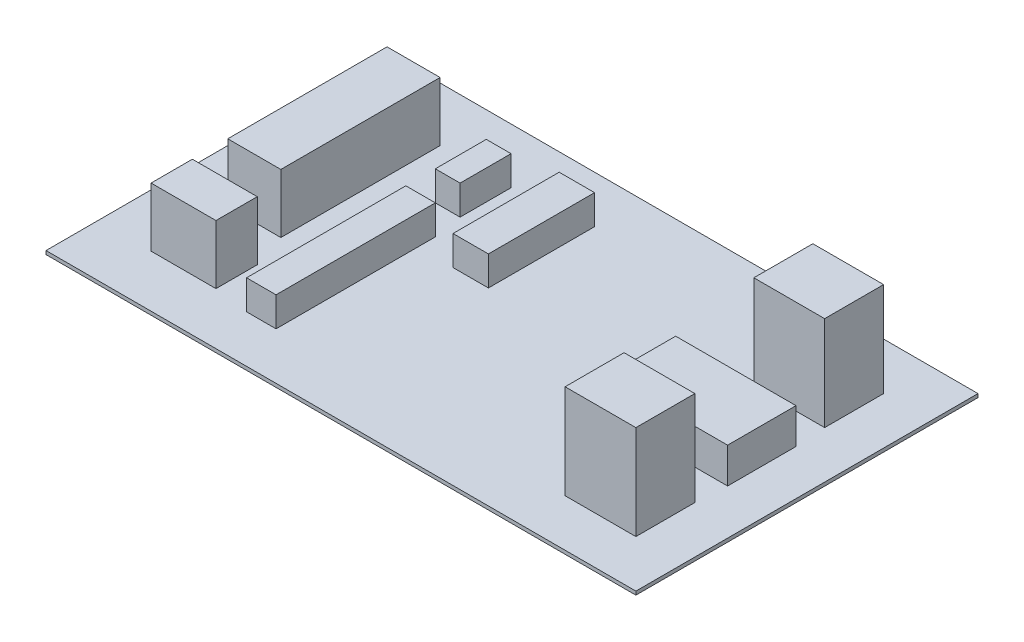
from build123d import *

# Parameters (mm, degrees)
SKETCH1_W           = 500
SKETCH1_H           = 290
BOSS_EXTRUDE1_DEPTH = 3
SKETCH3_W           = 60
SKETCH3_H           = 50
BOSS_EXTRUDE2_DEPTH = 80
SKETCH4_W           = 102
SKETCH4_H           = 58
BOSS_EXTRUDE3_DEPTH = 30
SKETCH5_W           = 30
SKETCH5_H           = 90
SKETCH5_W_2         = 21
SKETCH5_H_2         = 43.2
SKETCH5_W_3         = 25
SKETCH5_H_3         = 135
BOSS_EXTRUDE4_DEPTH = 25
SKETCH6_W           = 55
SKETCH6_H           = 35
SKETCH6_W_2         = 45
SKETCH6_H_2         = 135
BOSS_EXTRUDE5_DEPTH = 50


with BuildPart() as part:
    # Sketch1 → Boss-Extrude1 (new body)
    with BuildSketch(Plane(origin=(0, 0, 0), x_dir=(1, 0, 0), z_dir=(0, 1, 0))):
        with Locations((250, 145)):
            Rectangle(SKETCH1_W, SKETCH1_H)
    extrude(amount=BOSS_EXTRUDE1_DEPTH)

    # Sketch3 → Boss-Extrude2 (add)
    with BuildSketch(Plane(origin=(0, 3, 0), x_dir=(1, 0, 0), z_dir=(0, 1, 0))):
        with Locations((430, 225)):
            Rectangle(SKETCH3_W, SKETCH3_H)
        with Locations((430, 65)):
            Rectangle(SKETCH3_W, SKETCH3_H)
    extrude(amount=BOSS_EXTRUDE2_DEPTH)

    # Sketch4 → Boss-Extrude3 (add)
    with BuildSketch(Plane(origin=(0, 3, 0), x_dir=(1, 0, 0), z_dir=(0, 1, 0))):
        with Locations((410.73324546, 145)):
            Rectangle(SKETCH4_W, SKETCH4_H)
    extrude(amount=BOSS_EXTRUDE3_DEPTH)

    # Sketch5 → Boss-Extrude4 (add)
    with BuildSketch(Plane(origin=(0, 3, 0), x_dir=(1, 0, 0), z_dir=(0, 1, 0))):
        with Locations((200, 205)):
            Rectangle(SKETCH5_W, SKETCH5_H)
        with Locations((140.5, 221.6)):
            Rectangle(SKETCH5_W_2, SKETCH5_H_2)
        with Locations((142.5, 107.5)):
            Rectangle(SKETCH5_W_3, SKETCH5_H_3)
    extrude(amount=BOSS_EXTRUDE4_DEPTH)

    # Sketch6 → Boss-Extrude5 (add)
    with BuildSketch(Plane(origin=(0, 3, 0), x_dir=(1, 0, 0), z_dir=(0, 1, 0))):
        with Locations((72.5, 61.564484871)):
            Rectangle(SKETCH6_W, SKETCH6_H)
        with Locations((67.5, 176.564484871)):
            Rectangle(SKETCH6_W_2, SKETCH6_H_2)
    extrude(amount=BOSS_EXTRUDE5_DEPTH)


solid = part.part
